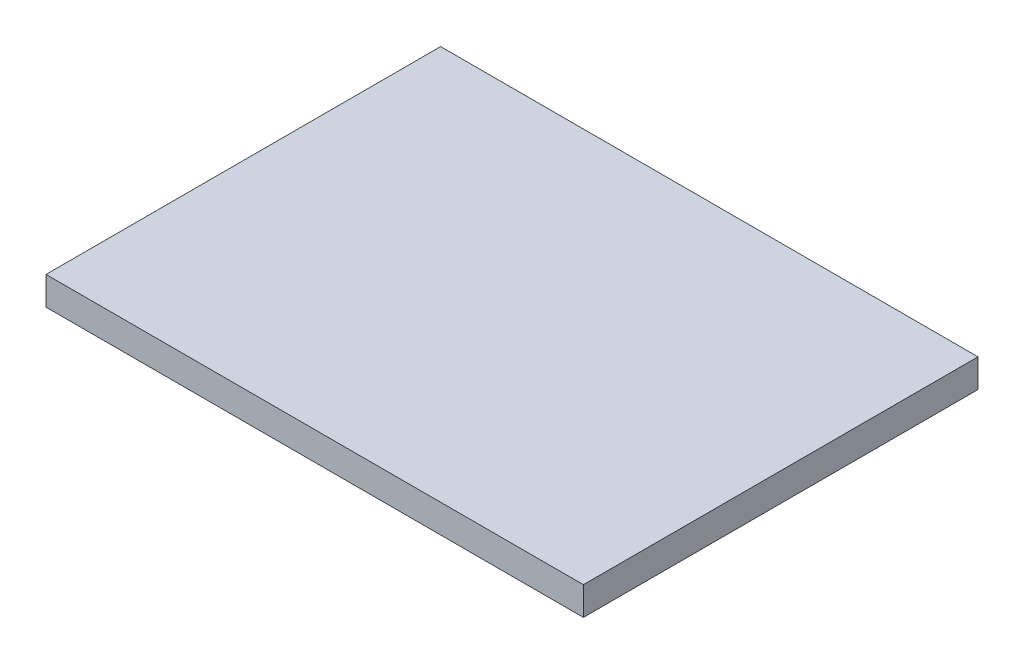
from build123d import *

# Parameters (mm, degrees)
SKETCH2_W           = 55.9
SKETCH2_H           = 41.05
BOSS_EXTRUDE2_DEPTH = 2.95


with BuildPart() as part:
    # Sketch2 → Boss-Extrude2 (new body)
    with BuildSketch(Plane(origin=(0, 0, 0), x_dir=(1, 0, 0), z_dir=(0, 1, 0))):
        with Locations((-5.189518072, -2.341169648)):
            Rectangle(SKETCH2_W, SKETCH2_H)
    extrude(amount=BOSS_EXTRUDE2_DEPTH)


solid = part.part
